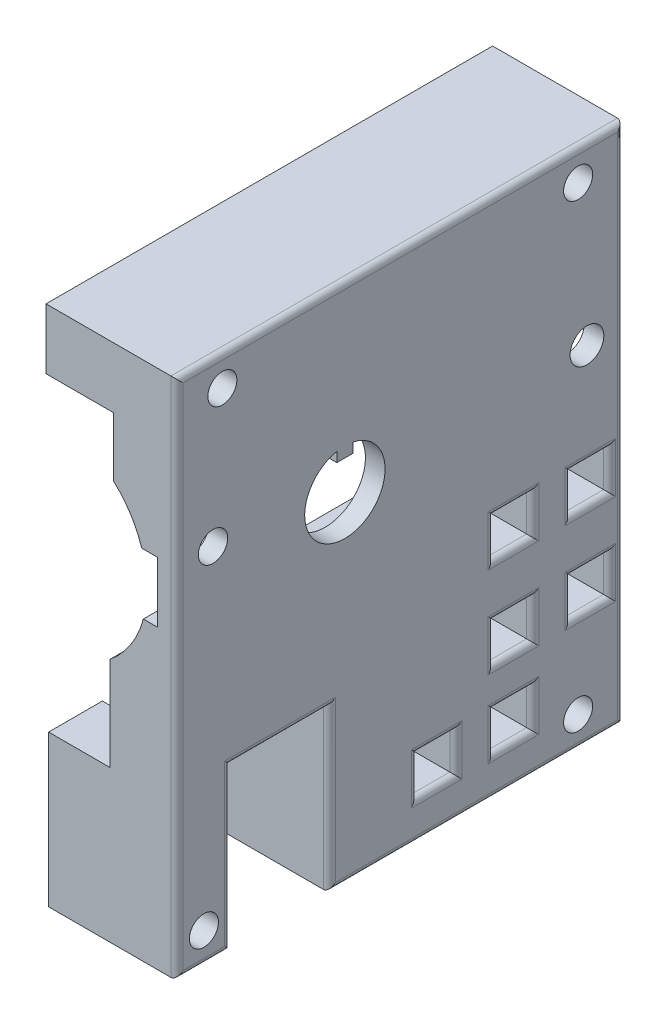
from build123d import *

# Parameters (mm, degrees)
PROFILEEXTRUDE_DEPTH = 73.76
HOSEWINDOW_W         = 16.29
HOSEWINDOW_H         = 26.5
HOSEWINDOWCUT_DEPTH  = 22.63
CAGESCREWS_R         = 2.4
CAGESCREWSCUT_DEPTH  = 22.63
AXLEHOLECUT_DEPTH    = 22.63
SETSCREWS_R          = 2.426338021
SETSCREWS_R_2        = 2.788762315
SETSCREWSCUT_DEPTH   = 22.63
SKETCH1_W            = 6.35
SKETCH1_H            = 6.35
CUT_EXTRUDE1_DEPTH   = 22.63
FILLET1_R            = 1


with BuildPart() as part:
    # Profile → ProfileExtrude (new body)
    with BuildSketch(Plane.XY):
        with BuildLine():
            Line((-6.01073477, -58.62791746), (-6.01073477, -33.62791746))
            Line((-6.01073477, -33.62791746), (4.13926523, -33.62791746))
            Line((4.13926523, -33.62791746), (4.13926523, -18.13791746))
            ThreePointArc((4.13926523, -18.13791746), (7.563334043, -14.326029686), (9.63126523, -9.63791746))
            Line((9.63126523, -9.63791746), (11.94926523, -9.63791746))
            Line((11.94926523, -9.63791746), (11.94926523, 0.36208254))
            Line((11.94926523, 0.36208254), (9.35926523, 0.36208254))
            ThreePointArc((9.35926523, 0.36208254), (7.525939238, 4.313848402), (4.70926523, 7.63708254))
            Line((4.70926523, 7.63708254), (4.70926523, 17.41208254))
            Line((4.70926523, 17.41208254), (-6.44073477, 17.41208254))
            Line((-6.44073477, 17.41208254), (-6.44073477, 27.41208254))
            Line((-6.44073477, 27.41208254), (15.18926523, 27.41208254))
            Line((15.18926523, 27.41208254), (15.18926523, -58.62791746))
            Line((15.18926523, -58.62791746), (-6.01073477, -58.62791746))
        make_face()
    extrude(amount=PROFILEEXTRUDE_DEPTH)

    # HoseWindow → HoseWindowCut (cut, through all)
    with BuildSketch(Plane(origin=(15.18926523, 0, 0), x_dir=(0, 0, -1), z_dir=(1, 0, 0))):
        with Locations((-56.725, -45.37791746)):
            Rectangle(HOSEWINDOW_W, HOSEWINDOW_H)
    extrude(amount=-HOSEWINDOWCUT_DEPTH, mode=Mode.SUBTRACT)

    # CageScrews → CageScrewsCut (cut, through all)
    with BuildSketch(Plane(origin=(15.18926523, 0, 0), x_dir=(0, 0, -1), z_dir=(1, 0, 0))):
        with Locations((-66.26, 22.41208254)):
            Circle(CAGESCREWS_R)
        with Locations((-7.5, 22.41208254)):
            Circle(CAGESCREWS_R)
        with Locations((-7.5, -53.62791746)):
            Circle(CAGESCREWS_R)
        with Locations((-69.31, -53.62791746)):
            Circle(CAGESCREWS_R)
    extrude(amount=-CAGESCREWSCUT_DEPTH, mode=Mode.SUBTRACT)

    # AxleHole → AxleHoleCut (cut, through all)
    with BuildSketch(Plane(origin=(15.18926523, 0, 0), x_dir=(0, 0, -1), z_dir=(1, 0, 0))):
        with BuildLine():
            Line((-44.699, 2.307293484), (-47.361, 2.307293484))
            Line((-47.361, 2.307293484), (-47.361, 3.926293484))
            ThreePointArc((-47.361, 3.926293484), (-46.03, -9.21691746), (-44.699, 3.926293484))
            Line((-44.699, 3.926293484), (-44.699, 2.307293484))
        make_face()
    extrude(amount=-AXLEHOLECUT_DEPTH, mode=Mode.SUBTRACT)

    # SetScrews → SetScrewsCut (cut, through all)
    with BuildSketch(Plane(origin=(15.18926523, 0, 0), x_dir=(0, 0, -1), z_dir=(1, 0, 0))):
        with Locations((-67.80722939, 0.544946624)):
            Circle(SETSCREWS_R)
        with Locations((-6.04299884, -1.55824191)):
            Circle(SETSCREWS_R_2)
    extrude(amount=-SETSCREWSCUT_DEPTH, mode=Mode.SUBTRACT)

    # Sketch1 → Cut-Extrude1 (cut, through all)
    with BuildSketch(Plane(origin=(15.18926523, 0, 0), x_dir=(0, 0, -1), z_dir=(1, 0, 0))):
        with Locations((-18.175, -49.10291746)):
            Rectangle(SKETCH1_W, SKETCH1_H)
        with Locations((-30.875, -49.10291746)):
            Rectangle(SKETCH1_W, SKETCH1_H)
        with Locations((-5.475, -36.40291746)):
            Rectangle(SKETCH1_W, SKETCH1_H)
        with Locations((-18.175, -36.40291746)):
            Rectangle(SKETCH1_W, SKETCH1_H)
        with Locations((-5.475, -21.40291746)):
            Rectangle(SKETCH1_W, SKETCH1_H)
        with Locations((-18.175, -21.40291746)):
            Rectangle(SKETCH1_W, SKETCH1_H)
    extrude(amount=-CUT_EXTRUDE1_DEPTH, mode=Mode.SUBTRACT)

    # Fillet1
    fillet1_edges = [part.edges().sort_by_distance(p)[0] for p in [
        (15.18926523, -45.92791746, 18.175),
        (15.18926523, -49.10291746, 21.35),
        (15.18926523, -52.27791746, 18.175),
        (15.18926523, -49.10291746, 15),
        (15.18926523, -45.92791746, 30.875),
        (15.18926523, -49.10291746, 34.05),
        (15.18926523, -52.27791746, 30.875),
        (15.18926523, -49.10291746, 27.7),
        (15.18926523, -33.22791746, 5.475),
        (15.18926523, -36.40291746, 8.65),
        (15.18926523, -39.57791746, 5.475),
        (15.18926523, -36.40291746, 2.3),
        (15.18926523, -15.60791746, 0),
        (15.18926523, -33.22791746, 18.175),
        (15.18926523, -36.40291746, 21.35),
        (15.18926523, -39.57791746, 18.175),
        (15.18926523, -36.40291746, 15),
        (15.18926523, -18.22791746, 5.475),
        (15.18926523, -21.40291746, 8.65),
        (15.18926523, -24.57791746, 5.475),
        (15.18926523, -21.40291746, 2.3),
        (15.18926523, -18.22791746, 18.175),
        (15.18926523, -21.40291746, 21.35),
        (15.18926523, -24.57791746, 18.175),
        (15.18926523, -21.40291746, 15),
        (15.18926523, -58.62791746, 69.315),
        (15.18926523, 27.41208254, 36.88),
        (15.18926523, -58.62791746, 24.29),
        (15.18926523, -15.60791746, 73.76),
        (15.18926523, -45.37791746, 64.87),
        (15.18926523, -45.37791746, 48.58),
        (15.18926523, -32.12791746, 56.725),
    ]]
    fillet(fillet1_edges, radius=FILLET1_R)


solid = part.part
